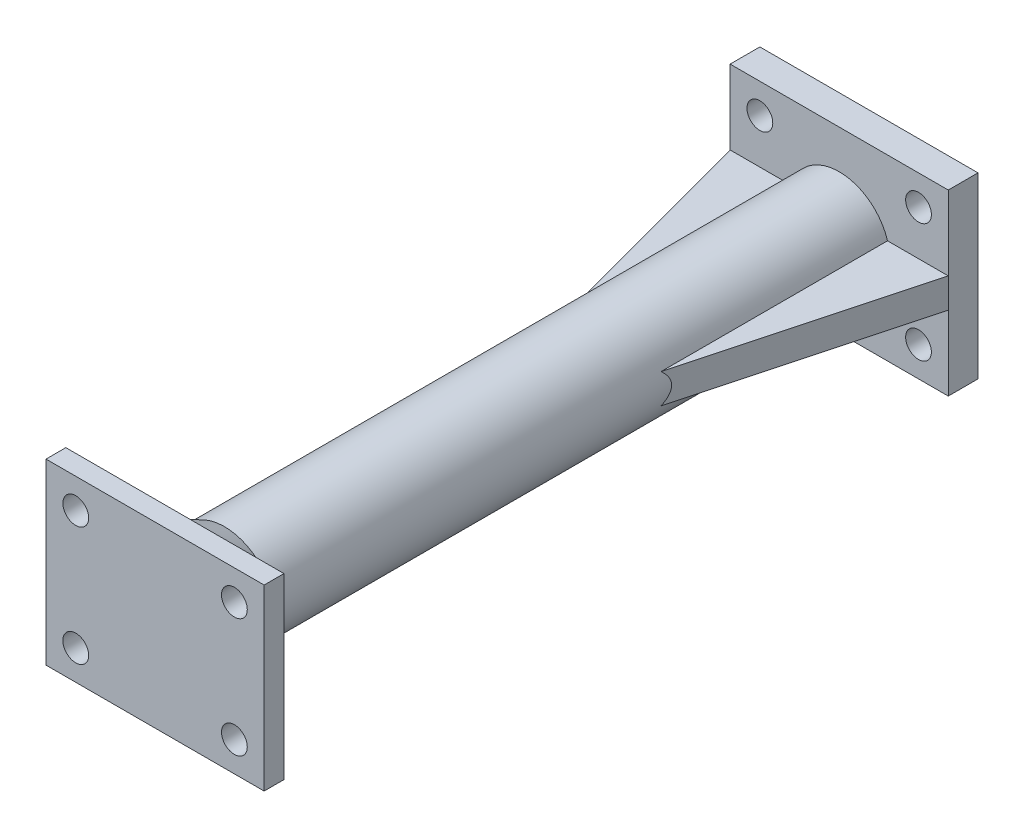
from build123d import *

# Parameters (mm, degrees)
SKETCH1_W           = 22
SKETCH1_H           = 18
SKETCH1_R           = 1.3
SKETCH1_R_2         = 5.1
BOSS_EXTRUDE1_DEPTH = 3
SKETCH1_3_R         = 5.1
BOSS_EXTRUDE2_DEPTH = 70
SKETCH2_W           = 22
SKETCH2_H           = 18
SKETCH2_R           = 1.3
BOSS_EXTRUDE3_DEPTH = 2
CHAMFER2_SIZE       = 5
CHAMFER2_SIZE2      = 2.331538291
RIB2_REACH          = 75.389
SKETCH3_WALL_W      = 171.556146136
SKETCH3_WALL_H      = 3
RIB3_REACH          = 75.389
SKETCH4_WALL_W      = 171.556146136
SKETCH4_WALL_H      = 3


with BuildPart() as part:
    # Sketch1 → Boss-Extrude1 (new body)
    with BuildSketch(Plane.XY):
        Rectangle(SKETCH1_W, SKETCH1_H)
        with Locations((8, 6)):
            Circle(SKETCH1_R, mode=Mode.SUBTRACT)
        with Locations((8, -6)):
            Circle(SKETCH1_R, mode=Mode.SUBTRACT)
        with Locations((-8, -6)):
            Circle(SKETCH1_R, mode=Mode.SUBTRACT)
        with Locations((-8, 6)):
            Circle(SKETCH1_R, mode=Mode.SUBTRACT)
        Circle(SKETCH1_R_2, mode=Mode.SUBTRACT)
    extrude(amount=BOSS_EXTRUDE1_DEPTH)

    # Sketch1_3 → Boss-Extrude2 (add)
    with BuildSketch(Plane.XY):
        Circle(SKETCH1_3_R)
    extrude(amount=BOSS_EXTRUDE2_DEPTH)

    # Sketch2 → Boss-Extrude3 (add)
    with BuildSketch(Plane.XY.offset(70)):
        Rectangle(SKETCH2_W, SKETCH2_H)
        with Locations((-8, 6)):
            Circle(SKETCH2_R, mode=Mode.SUBTRACT)
        with Locations((-8, -6)):
            Circle(SKETCH2_R, mode=Mode.SUBTRACT)
        with Locations((8, -6)):
            Circle(SKETCH2_R, mode=Mode.SUBTRACT)
        with Locations((8, 6)):
            Circle(SKETCH2_R, mode=Mode.SUBTRACT)
    extrude(amount=BOSS_EXTRUDE3_DEPTH)

    # Chamfer2
    chamfer2_edges = [part.edges().sort_by_distance(p)[0] for p in [
        (-5.1, 0, 70),
    ]]
    chamfer2_side = [part.faces().sort_by_distance(p)[0] for p in [
        (-5.1, 0, 36.5),
    ]]
    chamfer(chamfer2_edges, length=CHAMFER2_SIZE, length2=CHAMFER2_SIZE2, reference=chamfer2_side[0])

    # Sketch3 wall → Rib2 (add, up to next)
    with BuildSketch(Plane(origin=(-8.05, 0, 14), x_dir=(0.259028674037, 0, 0.965869632003), z_dir=(0.965869632003, 0, -0.259028674037)), mode=Mode.PRIVATE) as rib2_sk1:
        Rectangle(SKETCH3_WALL_W, SKETCH3_WALL_H)
    rib2_tool1 = extrude(rib2_sk1.sketch, amount=RIB2_REACH, mode=Mode.PRIVATE) - part.part
    add(rib2_tool1.solids().sort_by_distance((-8.05, 0, 14))[0])

    # Sketch4 wall → Rib3 (add, up to next)
    with BuildSketch(Plane(origin=(8.05, 0, 14), x_dir=(-0.259028674037, 0, 0.965869632003), z_dir=(0.965869632003, 0, 0.259028674037)), mode=Mode.PRIVATE) as rib3_sk1:
        Rectangle(SKETCH4_WALL_W, SKETCH4_WALL_H)
    rib3_tool1 = extrude(rib3_sk1.sketch, amount=-RIB3_REACH, mode=Mode.PRIVATE) - part.part
    add(rib3_tool1.solids().sort_by_distance((8.05, 0, 14))[0])


solid = part.part
